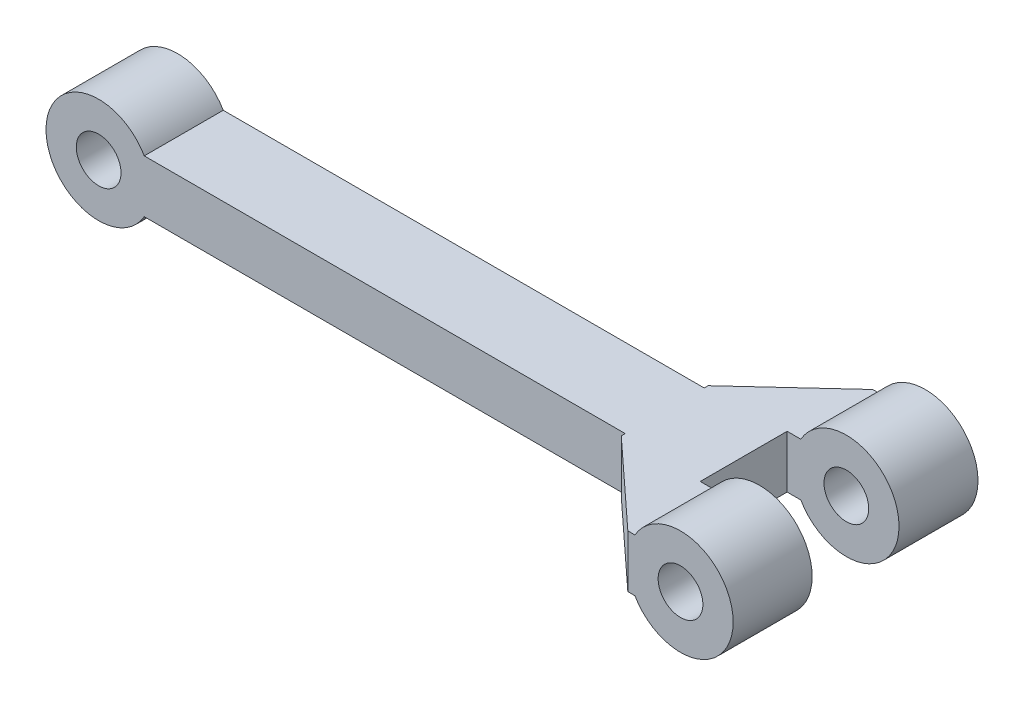
from build123d import *

# Parameters (mm, degrees)
SKETCH_1_R           = 4
SKETCH_1_R_2         = 1.7
EXTRUDE_1_DEPTH      = 6
EXTRUDE_2_DEPTH      = 2
EXTRUDE_2_DEPTH_BACK = 2
EXTRUDE_3_DEPTH      = 3
EXTRUDE_3_DEPTH_BACK = 3
SKETCH_3_R           = 1.7


with BuildPart() as part:
    # Эскиз1 → Бобышка-Вытянуть1 (new body)
    with BuildSketch(Plane.XY):
        Circle(SKETCH_1_R)
        Circle(SKETCH_1_R_2, mode=Mode.SUBTRACT)
    extrude_1 = extrude(amount=EXTRUDE_1_DEPTH)

    # Эскиз2 → Бобышка-Вытянуть2 (add, two sides: drawn at the far end of the back side and taken through both)
    with BuildSketch(Plane(origin=(0, 0, 0), x_dir=(1, 0, 0), z_dir=(0, 1, 0)).offset(-EXTRUDE_2_DEPTH_BACK)):
        Polygon((-4, 0), (-10.5, -6), (-10.5, -12.6), (-4, -18.6), (-3, -18.6), (-3, -12.6), (-4, -12.6), (-4.5, -12.6), (-4.5, -6), (-4, -6), (-3, -6), (-3, 0), align=None)
    extrude(amount=EXTRUDE_2_DEPTH + EXTRUDE_2_DEPTH_BACK)

    # Зеркальное отражение1: Бобышка-Вытянуть1 across plane
    add(extrude_1.mirror(Plane(origin=(0, 0, 9.3), x_dir=(1, 0, 0), z_dir=(0, 0, -1))))

    # Эскиз3 → Бобышка-Вытянуть3 (add, two sides: drawn at the far end of the back side and taken through both)
    with BuildSketch(Plane(origin=(0, 0, 9.3), x_dir=(-1, 0, 0), z_dir=(0, 0, -1)).offset(-EXTRUDE_3_DEPTH_BACK)):
        with BuildLine():
            Line((10.5, 2), (47.035898385, 2))
            ThreePointArc((47.035898385, 2), (54.5, 0), (47.035898385, -2))
            Line((47.035898385, -2), (10.5, -2))
            Line((10.5, -2), (10.5, 2))
        make_face()
        with Locations((50.5, 0)):
            Circle(SKETCH_3_R, mode=Mode.SUBTRACT)
    extrude(amount=EXTRUDE_3_DEPTH + EXTRUDE_3_DEPTH_BACK)


solid = part.part
